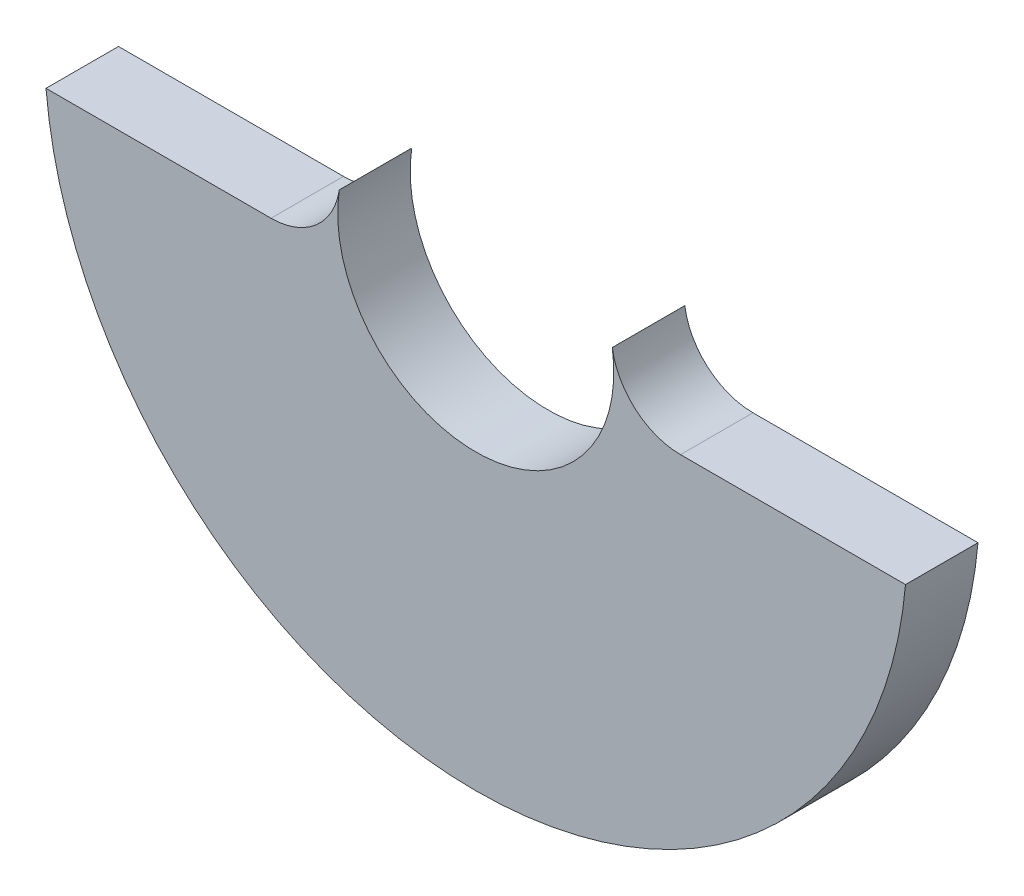
from build123d import *

# Parameters (mm, degrees)
SKETCH1_R           = 25
SKETCH1_R_2         = 8
BASE_EXTRUDE_DEPTH  = 4.2
CUT_EXTRUDE1_DEPTH  = 5.2
BOSS_EXTRUDE1_DEPTH = 4.2


with BuildPart() as part:
    # Sketch1 → Base-Extrude (new body)
    with BuildSketch(Plane.XY):
        Circle(SKETCH1_R)
        Circle(SKETCH1_R_2, mode=Mode.SUBTRACT)
    extrude(amount=BASE_EXTRUDE_DEPTH)

    # Sketch2 → Cut-Extrude1 (cut, through all)
    with BuildSketch(Plane.XY.offset(4.2)):
        Polygon((-31.283198073, -2.2), (32.499555714, -2.2), (32.499555714, 32.618237466), (-31.739332188, 32.618237466), align=None)
    extrude(amount=-CUT_EXTRUDE1_DEPTH, mode=Mode.SUBTRACT)

    # Sketch3 → Boss-Extrude1 (add)
    with BuildSketch(Plane.XY.offset(4.2)):
        with BuildLine():
            Line((7.691553809, -2.2), (11.86423196, -2.2))
            ThreePointArc((11.86423196, -2.2), (9.256550998, -1.233150178), (7.909487973, 1.2))
            ThreePointArc((7.909487973, 1.2), (7.983616109, -0.511736089), (7.691553809, -2.2))
        make_face()
        with BuildLine():
            Line((-11.86423196, -2.2), (-7.691553809, -2.2))
            ThreePointArc((-7.691553809, -2.2), (-7.983616109, -0.511736089), (-7.909487973, 1.2))
            ThreePointArc((-7.909487973, 1.2), (-9.256550998, -1.233150178), (-11.86423196, -2.2))
        make_face()
    extrude(amount=-BOSS_EXTRUDE1_DEPTH)


solid = part.part
